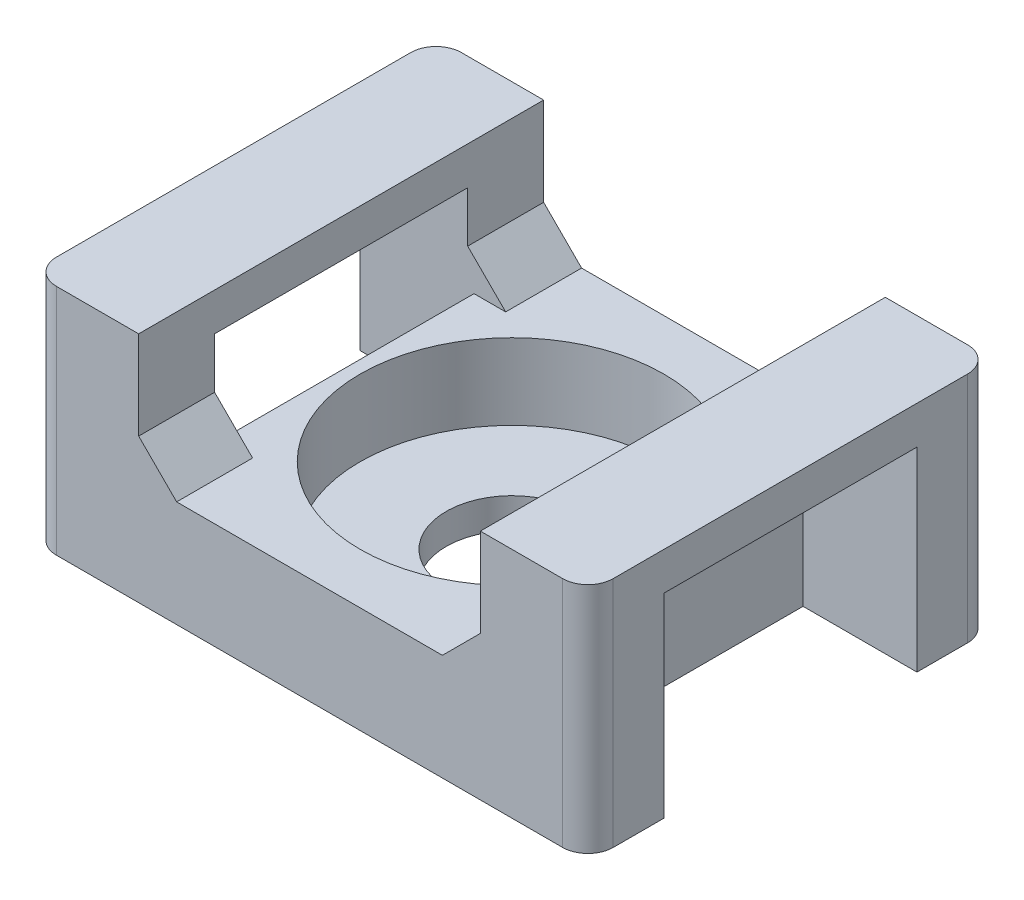
from build123d import *

# Parameters (mm, degrees)
EXTRUDE_1_DEPTH             = 8
CUT_EXTRUDE_1_DEPTH         = 5
HOLE_WIZARD_M51_D           = 5.2
HOLE_WIZARD_M51_DEPTH       = 4.2
HOLE_WIZARD_M51_CBORE_D     = 12
HOLE_WIZARD_M51_CBORE_DEPTH = 3
FILLET_1_R                  = 1


with BuildPart() as part:
    # Эскиз1 → Бобышка-Вытянуть1 (new body, symmetric)
    with BuildSketch(Plane.XY):
        Polygon((11, 0), (-11, 0), (-11, 9.2), (-6.75, 9.2), (-6.75, 5.7), (-5.25, 4.2), (5.25, 4.2), (6.75, 5.7), (6.75, 9.2), (11, 9.2), align=None)
    extrude(amount=EXTRUDE_1_DEPTH, both=True)

    # Эскиз2 → Вырез-Вытянуть1 (cut, symmetric)
    with BuildSketch(Plane.XY):
        Polygon((-11, 7.7), (-6.75, 7.7), (-6.75, 5.7), (-5.25, 4.2), (-6.5, 4.2), (-6.5, 0), (-11, 0), align=None)
    cut_extrude_1 = extrude(amount=CUT_EXTRUDE_1_DEPTH, both=True, mode=Mode.SUBTRACT)

    # Зеркальное отражение1: Вырез-Вытянуть1 across plane
    add(cut_extrude_1.mirror(Plane(origin=(0, 0, 0), x_dir=(0, 0, 1), z_dir=(1, 0, 0))), mode=Mode.SUBTRACT)

    # Цековка для  болта с шестигранной головкой M51
    with Locations(Plane(origin=(0, 4.2, 0), x_dir=(1, 0, 0), z_dir=(0, 1, 0))):
        with Locations((0, 0)):
            CounterBoreHole(HOLE_WIZARD_M51_D / 2, HOLE_WIZARD_M51_CBORE_D / 2, HOLE_WIZARD_M51_CBORE_DEPTH, depth=HOLE_WIZARD_M51_DEPTH)

    # Скругление1
    fillet_1_edges = [part.edges().sort_by_distance(p)[0] for p in [
        (11, 4.6, 8),
        (11, 4.6, -8),
        (-11, 4.6, -8),
        (-11, 4.6, 8),
    ]]
    fillet(fillet_1_edges, radius=FILLET_1_R)


solid = part.part
